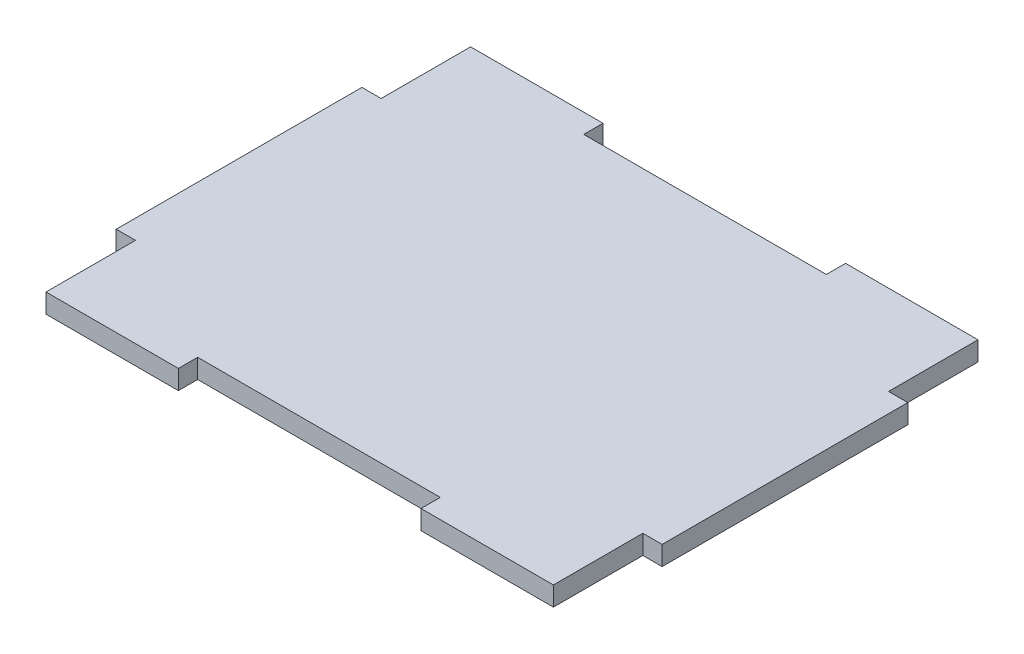
from build123d import *

# Parameters (mm, degrees)
SKETCH1_W           = 21.825
SKETCH1_H           = 3.175
SKETCH1_W_2         = 3.175
SKETCH1_H_2         = 40.5
BOSS_EXTRUDE1_DEPTH = 3.175


with BuildPart() as part:
    # Sketch1 → Boss-Extrude1 (new body)
    with BuildSketch(Plane(origin=(0, 0, 0), x_dir=(1, 0, 0), z_dir=(0, 1, 0))):
        Polygon((-20, 31.825), (-41.825, 31.825), (-41.825, 20.25), (-41.825, -20.25), (-41.825, -31.825), (-20, -31.825), (20, -31.825), (41.825, -31.825), (41.825, -20.25), (41.825, 20.25), (41.825, 31.825), (20, 31.825), align=None)
        with Locations((-30.9125, -33.4125)):
            Rectangle(SKETCH1_W, SKETCH1_H)
        with Locations((30.9125, -33.4125)):
            Rectangle(SKETCH1_W, SKETCH1_H)
        with Locations((43.4125, 0)):
            Rectangle(SKETCH1_W_2, SKETCH1_H_2)
        with Locations((30.9125, 33.4125)):
            Rectangle(SKETCH1_W, SKETCH1_H)
        with Locations((-30.9125, 33.4125)):
            Rectangle(SKETCH1_W, SKETCH1_H)
        with Locations((-43.4125, 0)):
            Rectangle(SKETCH1_W_2, SKETCH1_H_2)
    extrude(amount=BOSS_EXTRUDE1_DEPTH)


solid = part.part
